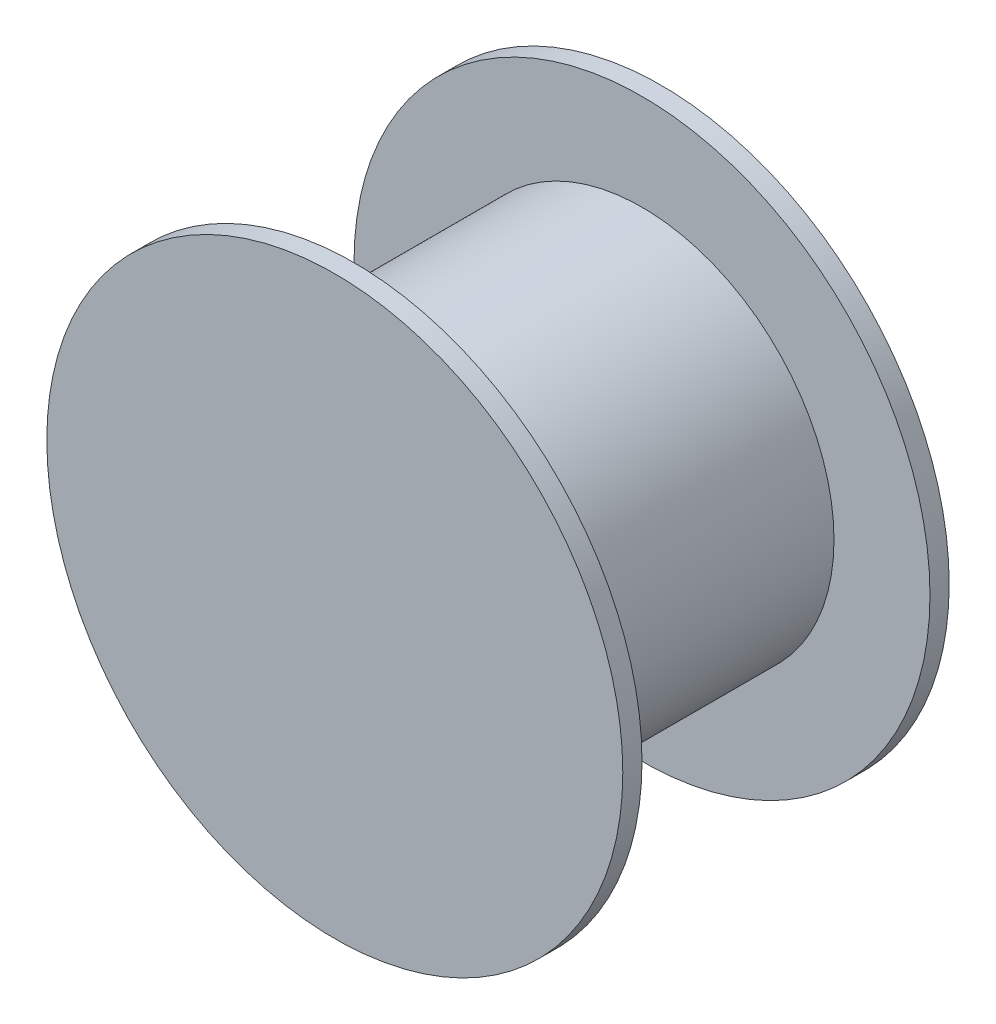
from build123d import *

# Parameters (mm, degrees)
SKETCH1_R           = 10
BOSS_EXTRUDE1_DEPTH = 16
SKETCH2_R           = 15
BOSS_EXTRUDE2_DEPTH = 1
SCALE1_SCALE        = 0.2
SCALE2_SCALE        = 2


with BuildPart() as part:
    # Sketch1 → Boss-Extrude1 (new body)
    with BuildSketch(Plane.XY):
        Circle(SKETCH1_R)
    extrude(amount=BOSS_EXTRUDE1_DEPTH)

    # Sketch2 → Boss-Extrude2 (add)
    with BuildSketch(Plane.XY.offset(16)):
        Circle(SKETCH2_R)
    boss_extrude2 = extrude(amount=-BOSS_EXTRUDE2_DEPTH)

    # Mirror1: Boss-Extrude2 across plane
    add(boss_extrude2.mirror(Plane(origin=(0, 0, 7.5), x_dir=(1, 0, 0), z_dir=(0, 0, -1))))


with BuildPart() as part_1:
    # Scale1: scaled about (0, 0, 7.5)
    add(part.part.scale(SCALE1_SCALE).moved(Location((0, 0, 6))))


with BuildPart() as part_2:
    # Scale2: scaled about (0, 0, 7.5)
    add(part_1.part.scale(SCALE2_SCALE).moved(Location((0, 0, -7.5))))


solid = part_2.part
